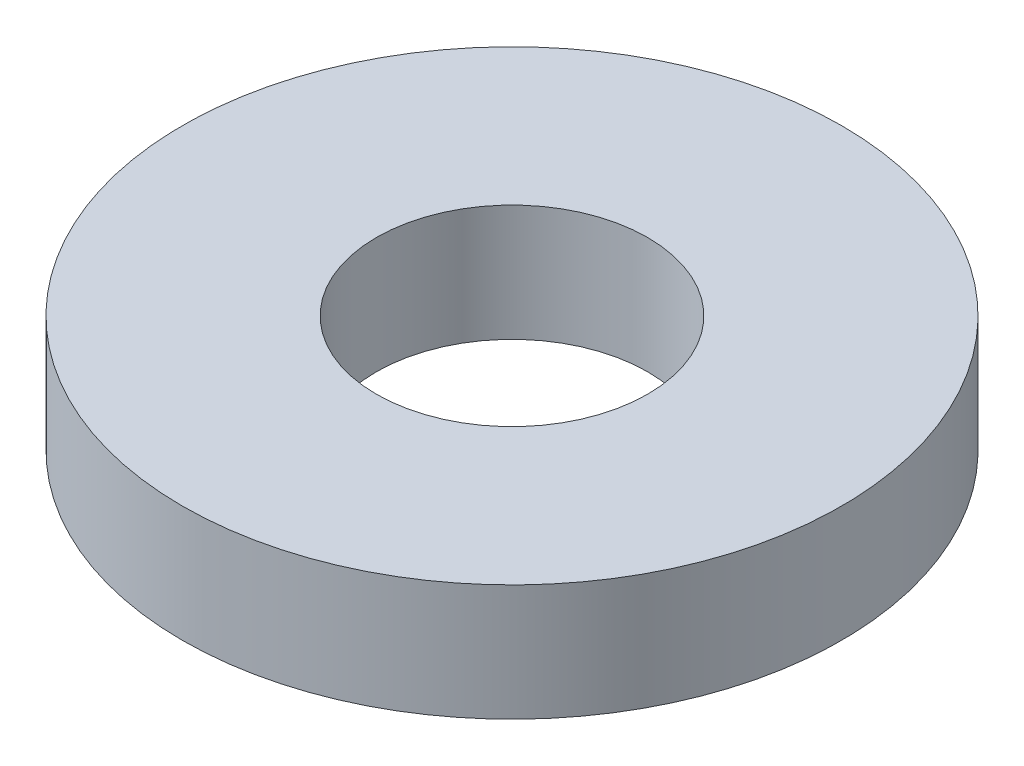
from build123d import *

# Parameters (mm, degrees)
ESBO_O1_R                = 4.25
ESBO_O1_R_2              = 1.75
RESSALTO_EXTRUS_O1_DEPTH = 1.5


with BuildPart() as part:
    # Esboço1 → Ressalto-extrusão1 (new body)
    with BuildSketch(Plane(origin=(0, 0, 0), x_dir=(1, 0, 0), z_dir=(0, 1, 0))):
        Circle(ESBO_O1_R)
        Circle(ESBO_O1_R_2, mode=Mode.SUBTRACT)
    extrude(amount=RESSALTO_EXTRUS_O1_DEPTH)


solid = part.part
